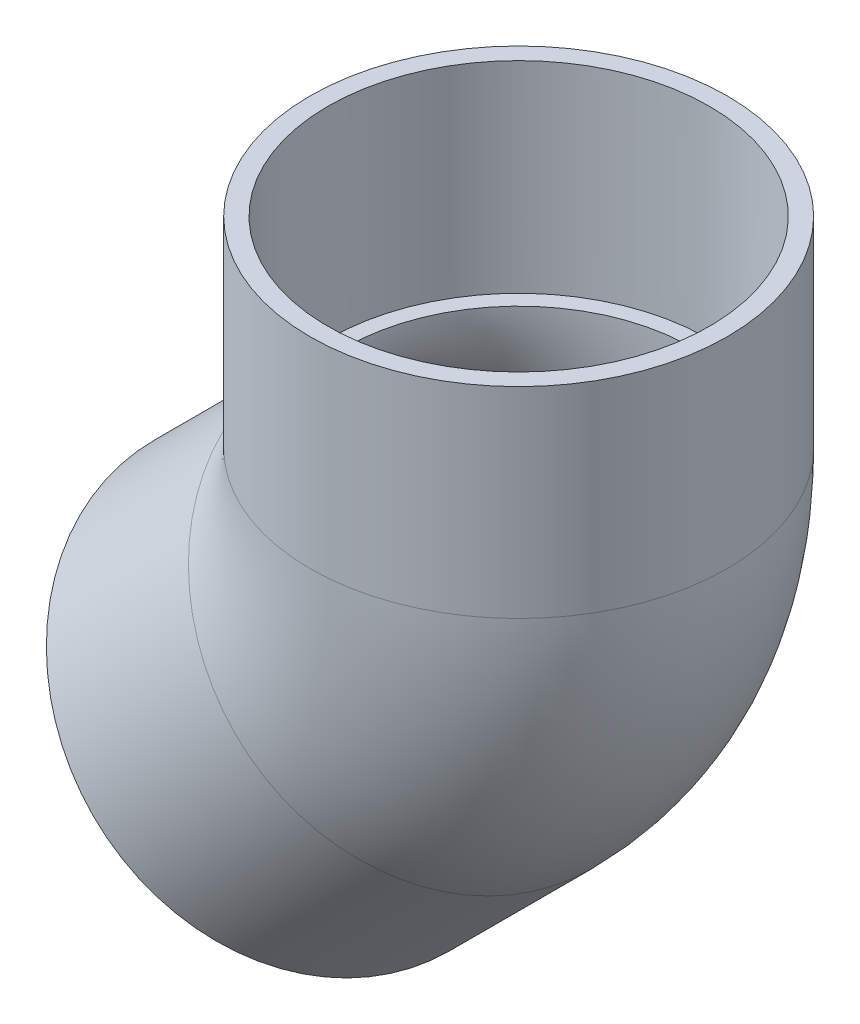
from build123d import *

# Parameters (mm, degrees)
SKETCH3_R   = 92.329
SKETCH3_R_2 = 77.0255


with BuildPart() as part:
    # Sketch1 → Revolve1 (revolve)
    with BuildSketch(Plane.XY):
        Polygon((-30.690025294, -161.262949294), (32.171767554, -98.401156447), (26.280719538, -92.510108431), (-36.284724857, -155.668249731), align=None)
    revolve(axis=Axis((-95.976487294, -95.976487294, 0), (0.7071067811865488, 0.7071067811865464, 0)))



with BuildPart() as body_2:
    # Sketch2 → Revolve2 (revolve)
    with BuildSketch(Plane.XY):
        Polygon((84.4169, 135.73125), (83.9978, 46.83125), (92.329, 46.83125), (92.329, 135.73125), align=None)
    revolve(axis=Axis((0, 0, 0), (0, 1, 0)))


with BuildPart() as part_1:
    add(part.part)

    add(body_2.part)  # Sweep1 merges body 2
    # Sweep1: sweep along a path in Sketch4
    with BuildLine(Plane.XY) as sweep1_path:
        ThreePointArc((-33.114694446, -33.114694446), (-8.606228687, 3.564816643), (0, 46.83125))
    # Sketch3 → Sweep1 (sweep)
    with BuildSketch(Plane(origin=(-33.114694446, -33.114694446, 0), x_dir=(0, 0, -1), z_dir=(0.7071067811865486, 0.7071067811865465, 0))):
        Circle(SKETCH3_R)
        Circle(SKETCH3_R_2, mode=Mode.SUBTRACT)
    sweep(path=sweep1_path.line)


solid = part_1.part
